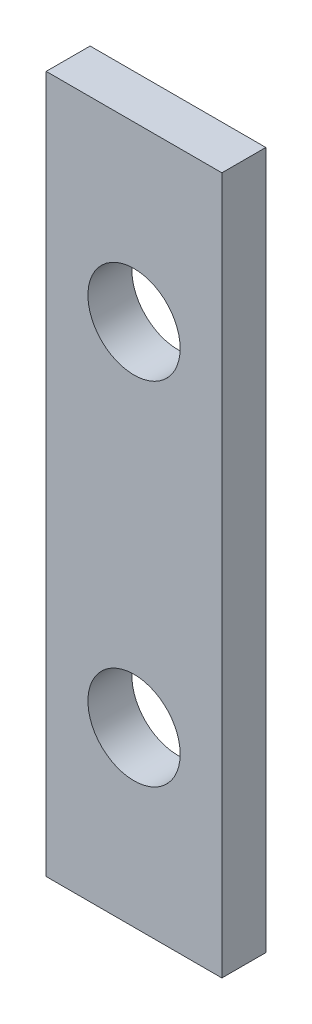
from build123d import *

# Parameters (mm, degrees)
SKETCH3_W           = 8
SKETCH3_H           = 2
BOSS_EXTRUDE2_DEPTH = 31.75
SKETCH4_R           = 2.1
CUT_EXTRUDE1_DEPTH  = 3


with BuildPart() as part:
    # Sketch3 → Boss-Extrude2 (new body)
    with BuildSketch(Plane(origin=(0, 0, 0), x_dir=(1, 0, 0), z_dir=(0, 1, 0))):
        with Locations((2.282032354, 3.507256135)):
            Rectangle(SKETCH3_W, SKETCH3_H)
    extrude(amount=BOSS_EXTRUDE2_DEPTH)

    # Sketch4 → Cut-Extrude1 (cut, through all)
    with BuildSketch(Plane.XY.offset(-2.507256135)):
        with Locations((2.282032354, 7.875)):
            Circle(SKETCH4_R)
        with Locations((2.282032354, 23.875)):
            Circle(SKETCH4_R)
    extrude(amount=-CUT_EXTRUDE1_DEPTH, mode=Mode.SUBTRACT)


solid = part.part
